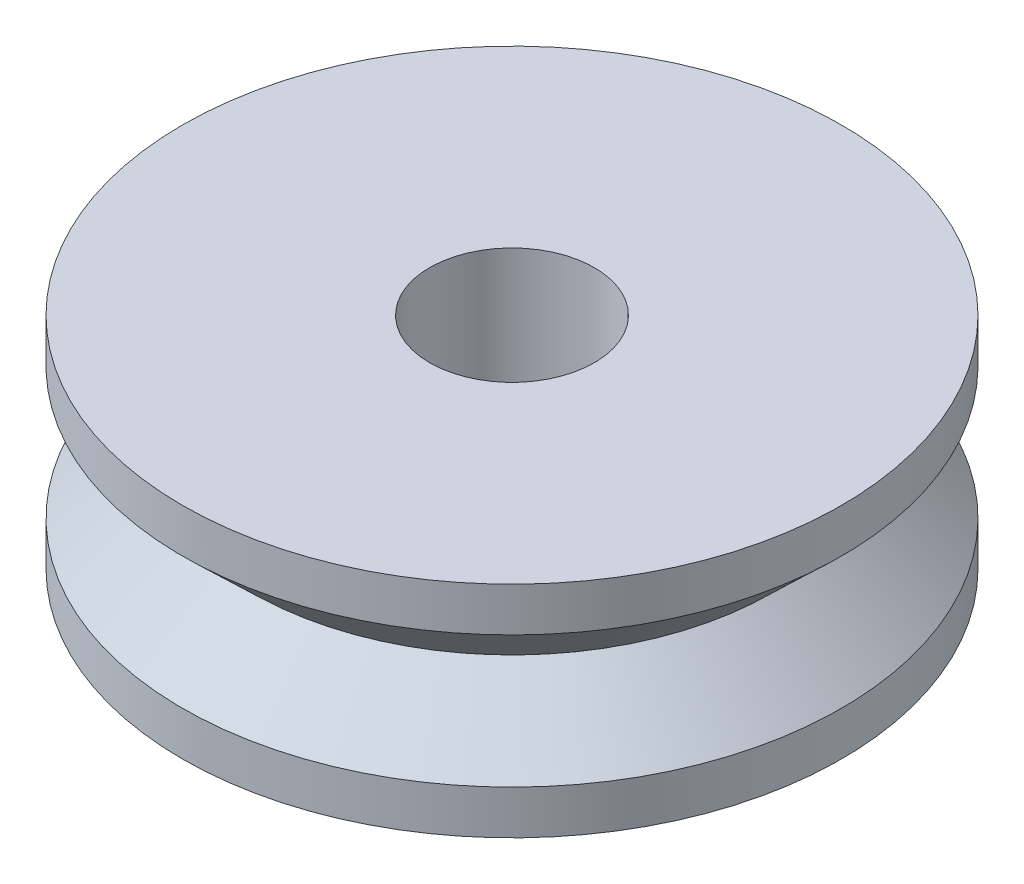
from build123d import *

# Parameters (mm, degrees)
SKETCH1_R           = 6
SKETCH1_R_2         = 1.5
BOSS_EXTRUDE1_DEPTH = 4


with BuildPart() as part:
    # Sketch1 → Boss-Extrude1 (new body)
    with BuildSketch(Plane(origin=(0, 0, 0), x_dir=(1, 0, 0), z_dir=(0, 1, 0))):
        Circle(SKETCH1_R)
        Circle(SKETCH1_R_2, mode=Mode.SUBTRACT)
    extrude(amount=BOSS_EXTRUDE1_DEPTH)

    # Cut-Sweep3: sweep along a path in Sketch3
    with BuildLine(Plane(origin=(0, 2, 0), x_dir=(1, 0, 0), z_dir=(0, 1, 0))) as cut_sweep3_path:
        CenterArc((0, 0), 6, 0, 360)
    # Sketch2 → Cut-Sweep3 (sweep, cut)
    with BuildSketch(Plane.XY):
        Polygon((-6, 3.2), (-6, 0.8), (-4.75, 2), align=None)
    sweep(path=cut_sweep3_path.line, mode=Mode.SUBTRACT)


solid = part.part
